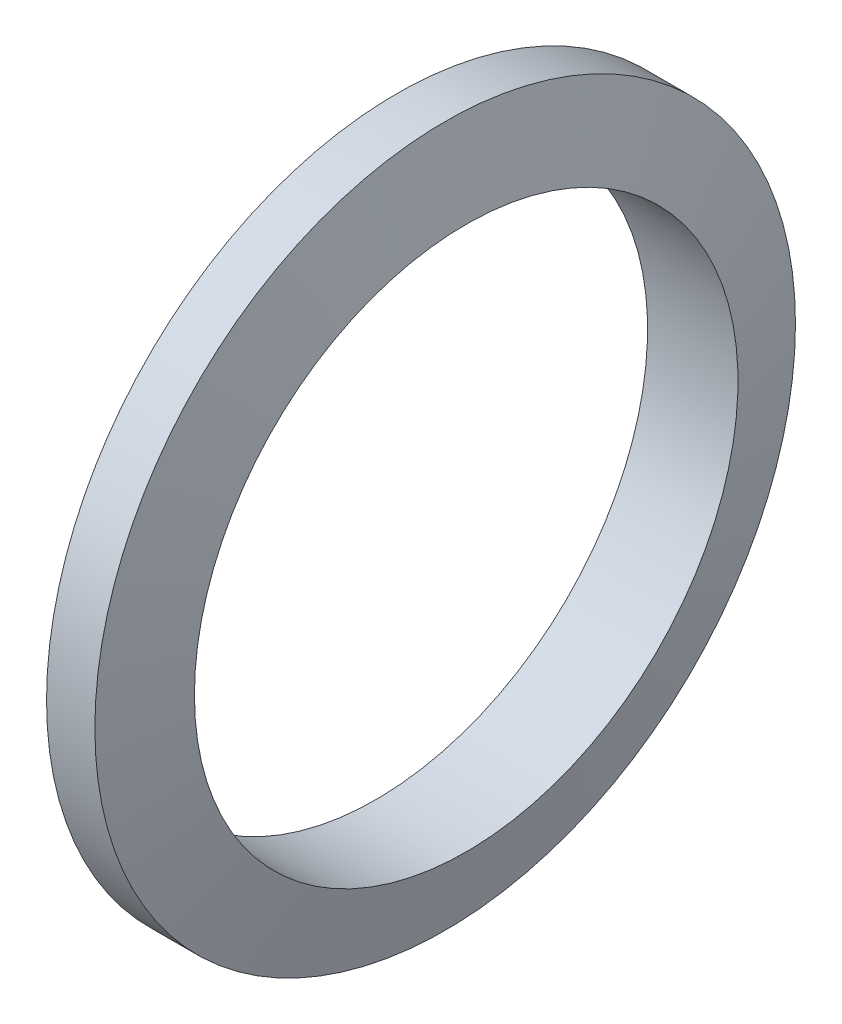
from build123d import *


with BuildPart() as part:
    # Ske → Revolve 314 (revolve)
    with BuildSketch(Plane.XY):
        Polygon((-2, 29), (2, 29), (3.741669751, 22.5), (-3.741669751, 22.5), align=None)
    revolve(axis=Axis((-10, 0, 0), (1, 0, 0)))


solid = part.part
